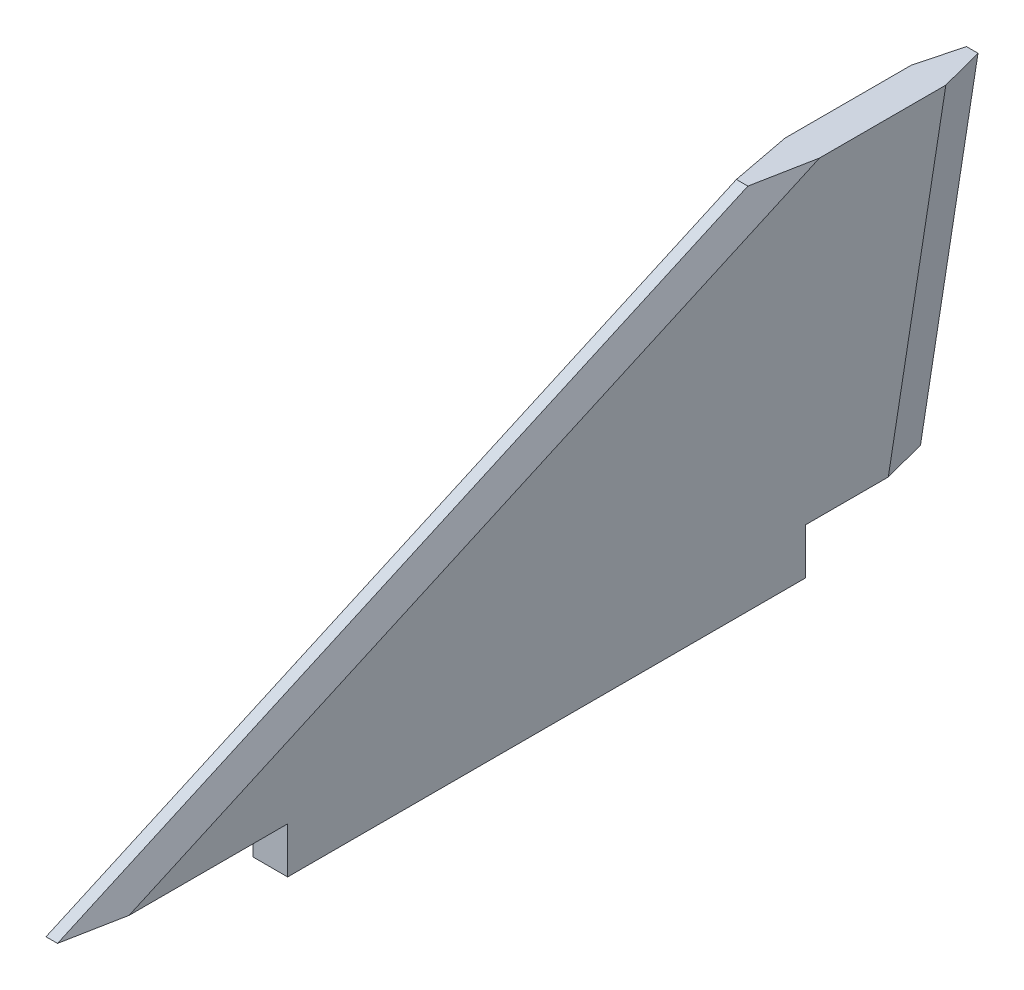
from build123d import *

# Parameters (mm, degrees)
BOSS_EXTRUDE1_DEPTH = 1.5
CHAMFER1_SIZE       = 1
CHAMFER1_SIZE2      = 3.732050808
CHAMFER2_SIZE       = 1
CHAMFER2_SIZE2      = 2.144506921


with BuildPart() as part:
    # Sketch1 → Boss-Extrude1 (new body, symmetric)
    with BuildSketch(Plane(origin=(0, 0, 0), x_dir=(0, 0, -1), z_dir=(1, 0, 0))):
        Polygon((45, 0), (0, 0), (0, 4), (-19, 4), (41, 31), (61, 31), (56, 4), (45, 4), align=None)
    extrude(amount=BOSS_EXTRUDE1_DEPTH, both=True)

    # Chamfer1
    chamfer1_edges = [part.edges().sort_by_distance(p)[0] for p in [
        (-1.5, 17.5, -58.5),
        (1.5, 17.5, -58.5),
    ]]
    chamfer1_side = [part.faces().sort_by_distance(p)[0] for p in [
        (0, 17.5, -58.5),
    ]]
    chamfer(chamfer1_edges, length=CHAMFER1_SIZE, length2=CHAMFER1_SIZE2, reference=chamfer1_side[0])

    # Chamfer2
    chamfer2_edges = [part.edges().sort_by_distance(p)[0] for p in [
        (-1.5, 17.5, -11),
        (1.5, 17.5, -11),
    ]]
    chamfer2_side = [part.faces().sort_by_distance(p)[0] for p in [
        (0, 17.5, -11),
    ]]
    chamfer(chamfer2_edges, length=CHAMFER2_SIZE, length2=CHAMFER2_SIZE2, reference=chamfer2_side[0])


solid = part.part
